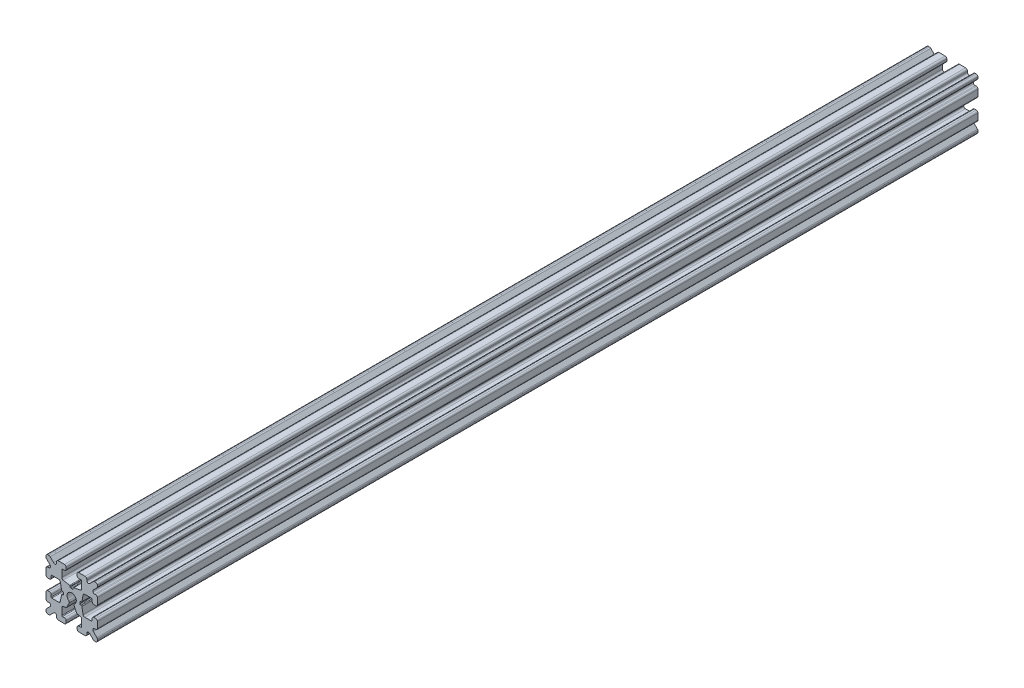
from build123d import *

# Parameters (mm, degrees)
SKETCH1_W           = 15
SKETCH1_H           = 15
SKETCH1_R           = 1.35
BOSS_EXTRUDE1_DEPTH = 128.55
FILLET1_R           = 0.5
CUT_EXTRUDE1_DEPTH  = 258.1
CUT_EXTRUDE3_DEPTH  = 258.1
FILLET3_R           = 0.5
FILLET4_R           = 0.5
FILLET5_R           = 3
FILLET6_R           = 0.2
CUT_EXTRUDE4_DEPTH  = 258.1
FILLET8_R           = 0.5
SKETCH6_W           = 6.249171159
SKETCH6_H           = 0.889
SKETCH6_W_2         = 0.889
SKETCH6_H_2         = 6.249171159
CUT_EXTRUDE5_DEPTH  = 258.1
CUT_EXTRUDE6_DEPTH  = 258.1
FILLET9_R           = 0.5
FILLET10_R          = 0.2


with BuildPart() as part:
    # Sketch1 → Boss-Extrude1 (new body, symmetric)
    with BuildSketch(Plane.XY):
        Rectangle(SKETCH1_W, SKETCH1_H)
        Circle(SKETCH1_R, mode=Mode.SUBTRACT)
    extrude(amount=BOSS_EXTRUDE1_DEPTH, both=True)

    # Fillet1
    fillet1_edges = [part.edges().sort_by_distance(p)[0] for p in [
        (7.5, -7.5, 0),
        (-7.5, -7.5, 0),
        (-7.5, 7.5, 0),
        (7.5, 7.5, 0),
    ]]
    fillet(fillet1_edges, radius=FILLET1_R)

    # Sketch2 → Cut-Extrude1 (cut, through all)
    with BuildSketch(Plane.XY.offset(128.55)):
        Polygon((-7.5, 1.6), (-6, 1.6), (-6, 2.9), (-3.4, 2.9), (-3.4, -2.9), (-6, -2.9), (-6, -1.6), (-7.5, -1.6), align=None)
        Polygon((2.9, 6), (1.6, 6), (1.6, 7.5), (-1.6, 7.5), (-1.6, 6), (-2.9, 6), (-2.9, 3.4), (2.9, 3.4), align=None)
        Polygon((-1.6, -7.5), (-1.6, -6), (-2.9, -6), (-2.9, -3.4), (2.9, -3.4), (2.9, -6), (1.6, -6), (1.6, -7.5), align=None)
        Polygon((6, -2.9), (6, -1.6), (7.5, -1.6), (7.5, 1.6), (6, 1.6), (6, 2.9), (3.4, 2.9), (3.4, -2.9), align=None)
    extrude(amount=-CUT_EXTRUDE1_DEPTH, mode=Mode.SUBTRACT)

    # Sketch4 → Cut-Extrude3 (cut, through all)
    with BuildSketch(Plane.XY.offset(128.55)):
        Polygon((-3.4, 2.9), (-2.85, 0), (-3.4, -2.9), align=None)
        Polygon((-2.9, 3.4), (0, 2.85), (2.9, 3.4), align=None)
        Polygon((3.4, 2.9), (2.85, 0), (3.4, -2.9), align=None)
        Polygon((-2.9, -3.4), (0, -2.85), (2.9, -3.4), align=None)
    extrude(amount=-CUT_EXTRUDE3_DEPTH, mode=Mode.SUBTRACT)

    # Fillet3
    fillet3_edges = [part.edges().sort_by_distance(p)[0] for p in [
        (1.6, -7.5, 0),
        (-1.6, -7.5, 0),
        (-1.6, -6, 0),
        (1.6, -6, 0),
        (6, 1.6, 0),
        (7.5, 1.6, 0),
        (7.5, -1.6, 0),
        (6, -1.6, 0),
        (-7.5, -1.6, 0),
        (-7.5, 1.6, 0),
        (-6, 1.6, 0),
        (-6, -1.6, 0),
        (-1.6, 6, 0),
        (-1.6, 7.5, 0),
        (1.6, 7.5, 0),
        (1.6, 6, 0),
    ]]
    fillet(fillet3_edges, radius=FILLET3_R)

    # Fillet4
    fillet4_edges = [part.edges().sort_by_distance(p)[0] for p in [
        (-2.9, -3.4, 0),
        (2.9, -3.4, 0),
        (3.4, -2.9, 0),
        (3.4, 2.9, 0),
        (-3.4, 2.9, 0),
        (-3.4, -2.9, 0),
        (2.9, 3.4, 0),
        (-2.9, 3.4, 0),
    ]]
    fillet(fillet4_edges, radius=FILLET4_R)

    # Fillet5
    fillet5_edges = [part.edges().sort_by_distance(p)[0] for p in [
        (-2.85, 0, 0),
        (0, 2.85, 0),
        (2.85, 0, 0),
        (0, -2.85, 0),
    ]]
    fillet(fillet5_edges, radius=FILLET5_R)

    # Fillet6
    fillet6_edges = [part.edges().sort_by_distance(p)[0] for p in [
        (-2.9, -6, 0),
        (2.9, -6, 0),
        (6, -2.9, 0),
        (6, 2.9, 0),
        (-6, 2.9, 0),
        (-6, -2.9, 0),
        (2.9, 6, 0),
        (-2.9, 6, 0),
    ]]
    fillet(fillet6_edges, radius=FILLET6_R)

    # Sketch5 → Cut-Extrude4 (cut, through all)
    with BuildSketch(Plane.XY.offset(128.55)):
        Polygon((-7.5, 6.439339828), (-5.460660172, 4.4), (-7.5, 4.4), align=None)
        Polygon((-6.439339828, 7.5), (-4.4, 5.460660172), (-4.4, 7.5), align=None)
        Polygon((4.4, 7.5), (6.439339828, 7.5), (4.4, 5.460660172), align=None)
        Polygon((7.5, 6.439339828), (7.5, 4.4), (5.460660172, 4.4), align=None)
        Polygon((7.5, -6.439339828), (5.460660172, -4.4), (7.5, -4.4), align=None)
        Polygon((6.439339828, -7.5), (4.4, -5.460660172), (4.4, -7.5), align=None)
        Polygon((-4.4, -7.5), (-6.439339828, -7.5), (-4.4, -5.460660172), align=None)
        Polygon((-7.5, -6.439339828), (-7.5, -4.4), (-5.460660172, -4.4), align=None)
    extrude(amount=-CUT_EXTRUDE4_DEPTH, mode=Mode.SUBTRACT)

    # Fillet8
    fillet8_edges = [part.edges().sort_by_distance(p)[0] for p in [
        (-7.5, 4.4, 0),
        (-7.5, 6.439339828, 0),
        (-5.460660172, 4.4, 0),
        (7.5, -4.4, 0),
        (7.5, -6.439339828, 0),
        (5.460660172, -4.4, 0),
        (5.460660172, 4.4, 0),
        (7.5, 6.439339828, 0),
        (7.5, 4.4, 0),
        (-4.4, 7.5, 0),
        (-4.4, 5.460660172, 0),
        (-6.439339828, 7.5, 0),
        (-5.460660172, -4.4, 0),
        (-7.5, -6.439339828, 0),
        (-7.5, -4.4, 0),
        (4.4, 5.460660172, 0),
        (4.4, 7.5, 0),
        (6.439339828, 7.5, 0),
        (6.439339828, -7.5, 0),
        (4.4, -7.5, 0),
        (4.4, -5.460660172, 0),
        (-6.439339828, -7.5, 0),
        (-4.4, -5.460660172, 0),
        (-4.4, -7.5, 0),
    ]]
    fillet(fillet8_edges, radius=FILLET8_R)

    # Sketch6 → Cut-Extrude5 (cut, through all)
    with BuildSketch(Plane.XY.offset(128.55)):
        with Locations((5.530603002, 0)):
            Rectangle(SKETCH6_W, SKETCH6_H)
        with Locations((-5.530603002, 0)):
            Rectangle(SKETCH6_W, SKETCH6_H)
        with Locations((0, 5.530603002)):
            Rectangle(SKETCH6_W_2, SKETCH6_H_2)
    extrude(amount=-CUT_EXTRUDE5_DEPTH, mode=Mode.SUBTRACT)

    # Sketch7 → Cut-Extrude6 (cut, through all)
    with BuildSketch(Plane.XY.offset(128.55)):
        Polygon((0, 0), (-2.153335353, -4.617842566), (2.153335353, -4.617842566), align=None)
    extrude(amount=-CUT_EXTRUDE6_DEPTH, mode=Mode.SUBTRACT)

    # Fillet9
    fillet9_edges = [part.edges().sort_by_distance(p)[0] for p in [
        (1.457911068, -3.126500375, 0),
        (-1.457911068, -3.126500375, 0),
        (-0.570534653, -1.223515512, 0),
        (0.570534653, -1.223515512, 0),
    ]]
    fillet(fillet9_edges, radius=FILLET9_R)

    # Fillet10
    fillet10_edges = [part.edges().sort_by_distance(p)[0] for p in [
        (-2.406017422, 0.4445, 0),
        (-2.406017422, -0.4445, 0),
        (0.4445, 2.406017422, 0),
        (-0.4445, 2.406017422, 0),
        (2.406017422, 0.4445, 0),
        (2.406017422, -0.4445, 0),
        (-2.93658978, -0.4445, 0),
        (-2.93658978, 0.4445, 0),
        (2.93658978, -0.4445, 0),
        (2.93658978, 0.4445, 0),
        (0.4445, 2.93658978, 0),
        (-0.4445, 2.93658978, 0),
    ]]
    fillet(fillet10_edges, radius=FILLET10_R)


solid = part.part
